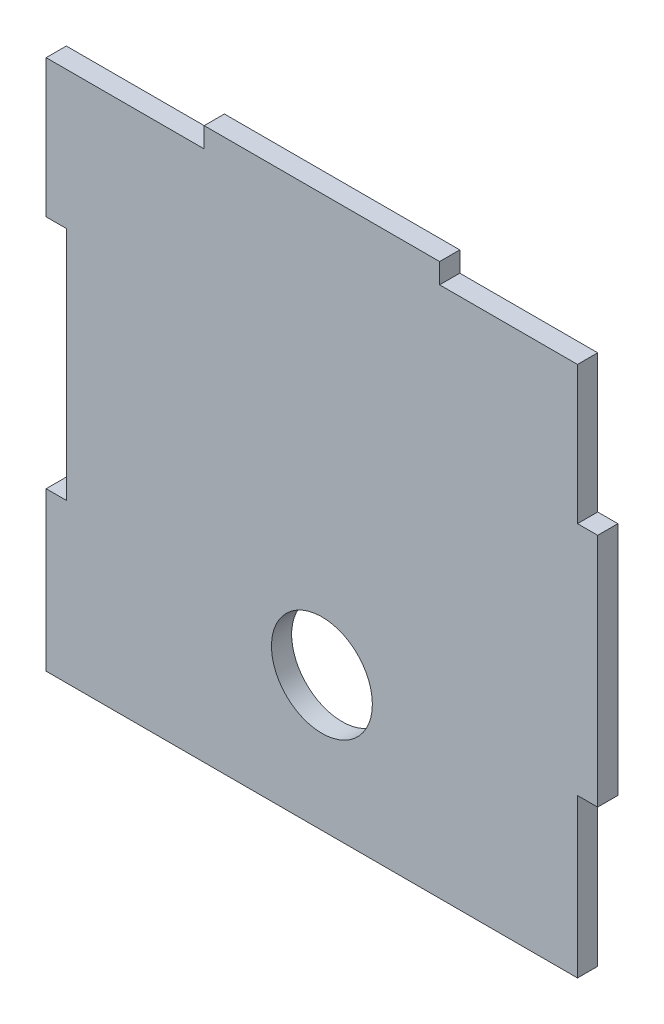
from build123d import *

# Parameters (mm, degrees)
BOSS_EXTRUDE1_DEPTH = 3
SKETCH2_R           = 7.5
CUT_EXTRUDE1_DEPTH  = 3


with BuildPart() as part:
    # Sketch1 → Boss-Extrude1 (new body)
    with BuildSketch(Plane.XY):
        Polygon((-38, 39.5), (-17.5, 39.5), (-17.5, 42.5), (17.5, 42.5), (17.5, 39.5), (38, 39.5), (38, 19), (41, 19), (41, 16), (41, -16), (38, -16), (38, -19), (38, -39.5), (-41, -39.5), (-41, -19), (-41, -16), (-38, -16), (-38, 16), (-38, 19), (-41, 19), (-41, 39.5), align=None)
    extrude(amount=BOSS_EXTRUDE1_DEPTH)

    # Sketch2 → Cut-Extrude1 (cut)
    with BuildSketch(Plane.XY.offset(3)):
        with Locations((0, -19.5)):
            Circle(SKETCH2_R)
    extrude(amount=-CUT_EXTRUDE1_DEPTH, mode=Mode.SUBTRACT)


solid = part.part
